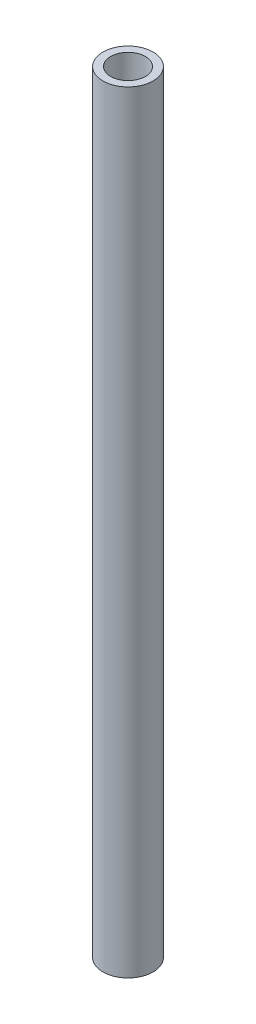
from build123d import *

# Parameters (mm, degrees)
SKETCH_1_R      = 6.5
SKETCH_1_R_2    = 4.5
EXTRUDE_1_DEPTH = 200


with BuildPart() as part:
    # Эскиз1 → Вытянуть-Тонкостенный1 (new body)
    with BuildSketch(Plane(origin=(0, 0, 0), x_dir=(1, 0, 0), z_dir=(0, 1, 0))):
        Circle(SKETCH_1_R)
        Circle(SKETCH_1_R_2, mode=Mode.SUBTRACT)
    extrude(amount=EXTRUDE_1_DEPTH)


solid = part.part
